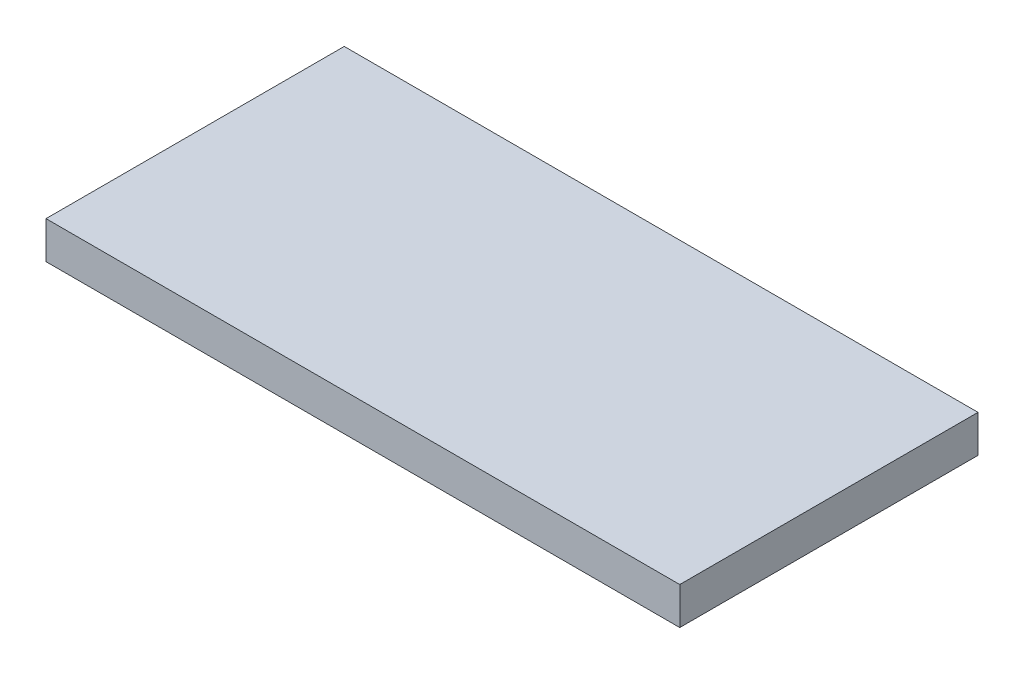
from build123d import *

# Parameters (mm, degrees)
CROQUIS1_W              = 85
CROQUIS1_H              = 40
SALIENTE_EXTRUIR1_DEPTH = 5


with BuildPart() as part:
    # Croquis1 → Saliente-Extruir1 (new body)
    with BuildSketch(Plane(origin=(0, 0, 0), x_dir=(1, 0, 0), z_dir=(0, 1, 0))):
        with Locations((1.63740458, -7.511450382)):
            Rectangle(CROQUIS1_W, CROQUIS1_H)
    extrude(amount=SALIENTE_EXTRUIR1_DEPTH)


solid = part.part
